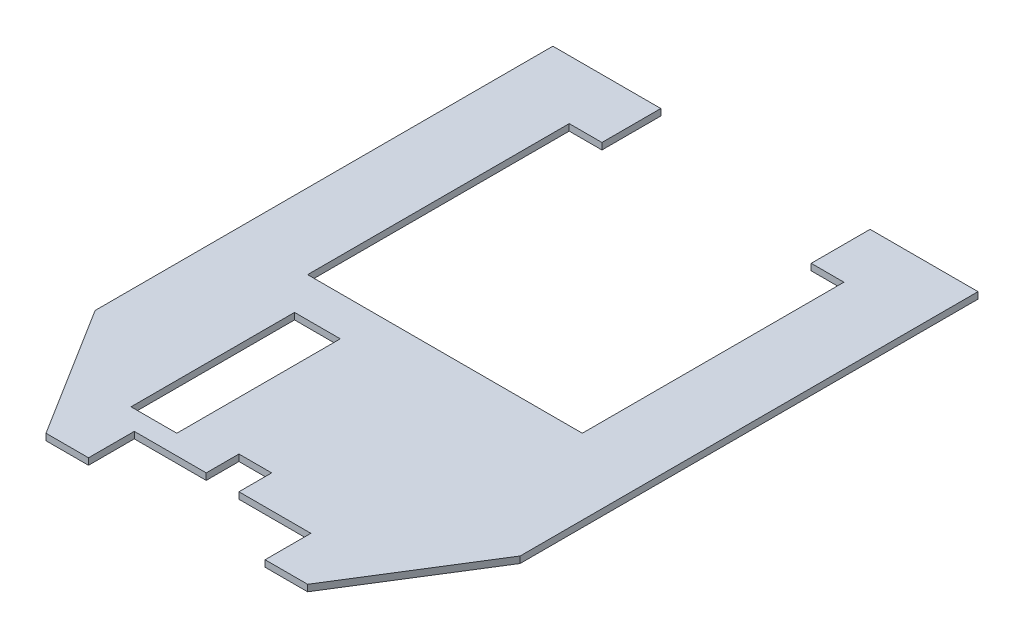
from build123d import *

# Parameters (mm, degrees)
SKETCH1_W      = 7
SKETCH1_H      = 25
EXTRUDE1_DEPTH = 1


with BuildPart() as part:
    # Sketch1 → Extrude1 (new body)
    with BuildSketch(Plane(origin=(0, 0, 0), x_dir=(1, 0, 0), z_dir=(0, 1, 0))):
        Polygon((-20, -20), (-13.5, -20), (-13.5, -13), (-2.5, -13), (-2.5, -8), (2.5, -8), (2.5, -13), (13.5, -13), (13.5, -20), (20, -20), (32.5, 0), (32.5, 70), (16, 70), (16, 61), (21, 61), (21, 21), (-21, 21), (-21, 61), (-16, 61), (-16, 70), (-32.5, 70), (-32.5, 0), align=None)
        with Locations((-13.5, 2.5)):
            Rectangle(SKETCH1_W, SKETCH1_H, mode=Mode.SUBTRACT)
    extrude(amount=EXTRUDE1_DEPTH)


solid = part.part
